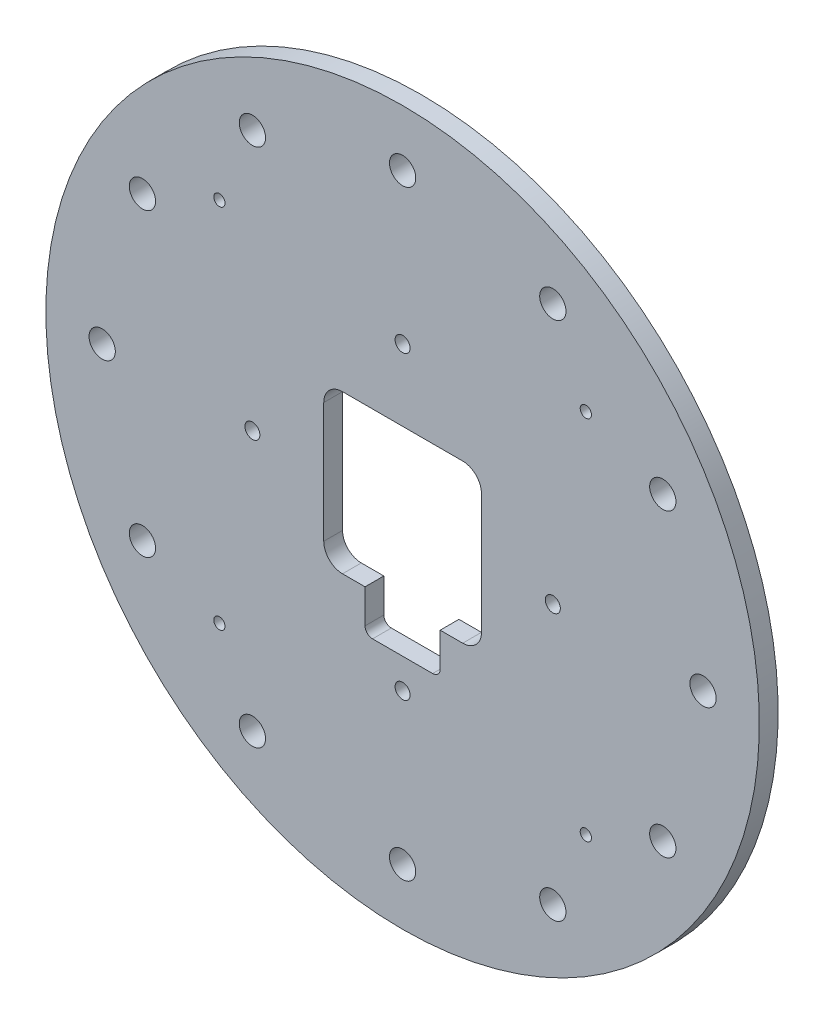
from build123d import *

# Parameters (mm, degrees)
SKETCH1_R             = 95
SKETCH1_R_2           = 1.5
SKETCH1_R_3           = 2
SKETCH1_R_4           = 3.5
BOSS_EXTRUDE1_DEPTH   = 5
BODY_MOVE_COPY1_ANGLE = 90


with BuildPart() as part:
    # Sketch1 → Boss-Extrude1 (new body)
    with BuildSketch(Plane(origin=(0, 0, 0), x_dir=(1, 0, 0), z_dir=(0, 1, 0))):
        Circle(SKETCH1_R)
        with Locations((48.790367902, 48.790367902)):
            Circle(SKETCH1_R_2, mode=Mode.SUBTRACT)
        with Locations((0, 40)):
            Circle(SKETCH1_R_3, mode=Mode.SUBTRACT)
        with Locations((40, 0)):
            Circle(SKETCH1_R_3, mode=Mode.SUBTRACT)
        with Locations((0, -40)):
            Circle(SKETCH1_R_3, mode=Mode.SUBTRACT)
        with Locations((-40, 0)):
            Circle(SKETCH1_R_3, mode=Mode.SUBTRACT)
        with Locations((48.790367902, -48.790367902)):
            Circle(SKETCH1_R_2, mode=Mode.SUBTRACT)
        with Locations((-48.790367902, -48.790367902)):
            Circle(SKETCH1_R_2, mode=Mode.SUBTRACT)
        with Locations((-48.790367902, 48.790367902)):
            Circle(SKETCH1_R_2, mode=Mode.SUBTRACT)
        with Locations((80, 0)):
            Circle(SKETCH1_R_4, mode=Mode.SUBTRACT)
        with Locations((69.282032303, -40)):
            Circle(SKETCH1_R_4, mode=Mode.SUBTRACT)
        with Locations((40, -69.282032303)):
            Circle(SKETCH1_R_4, mode=Mode.SUBTRACT)
        with Locations((0, -80)):
            Circle(SKETCH1_R_4, mode=Mode.SUBTRACT)
        with Locations((-40, -69.282032303)):
            Circle(SKETCH1_R_4, mode=Mode.SUBTRACT)
        with Locations((-69.282032303, -40)):
            Circle(SKETCH1_R_4, mode=Mode.SUBTRACT)
        with Locations((-80, 0)):
            Circle(SKETCH1_R_4, mode=Mode.SUBTRACT)
        with Locations((-69.282032303, 40)):
            Circle(SKETCH1_R_4, mode=Mode.SUBTRACT)
        with Locations((-40, 69.282032303)):
            Circle(SKETCH1_R_4, mode=Mode.SUBTRACT)
        with Locations((0, 80)):
            Circle(SKETCH1_R_4, mode=Mode.SUBTRACT)
        with Locations((40, 69.282032303)):
            Circle(SKETCH1_R_4, mode=Mode.SUBTRACT)
        with Locations((69.282032303, 40)):
            Circle(SKETCH1_R_4, mode=Mode.SUBTRACT)
        with BuildLine():
            Line((10, -21), (10, -30.000108076))
            ThreePointArc((10, -30.000108076), (9.414180319, -31.414301502), (7.999957489, -32.000050194))
            Line((7.999957489, -32.000050194), (-8.000158272, -32.000050194))
            ThreePointArc((-8.000158272, -32.000050194), (-9.414280711, -31.414259919), (-10, -30.000108076))
            Line((-10, -30.000108076), (-10, -21))
            Line((-10, -21), (-16.005742178, -21))
            ThreePointArc((-16.005742178, -21), (-19.538404995, -19.534344662), (-21, -16))
            Line((-21, -16), (-21, 16))
            ThreePointArc((-21, 16), (-19.535533906, 19.535533906), (-16, 21))
            Line((-16, 21), (16, 21))
            ThreePointArc((16, 21), (19.535388079, 19.536388365), (21.000355251, 16.001561768))
            Line((21.000355251, 16.001561768), (21.000355251, -16.001561768))
            ThreePointArc((21.000355251, -16.001561768), (19.536346588, -19.535991337), (16.001917019, -21))
            Line((16.001917019, -21), (10, -21))
        make_face(mode=Mode.SUBTRACT)
    extrude(amount=BOSS_EXTRUDE1_DEPTH)


with BuildPart() as part_1:
    # Body-Move/Copy1: moved
    add(part.part.rotate(Axis((0, 2.5, 0), (1, 0, 0)), BODY_MOVE_COPY1_ANGLE))


solid = part_1.part
